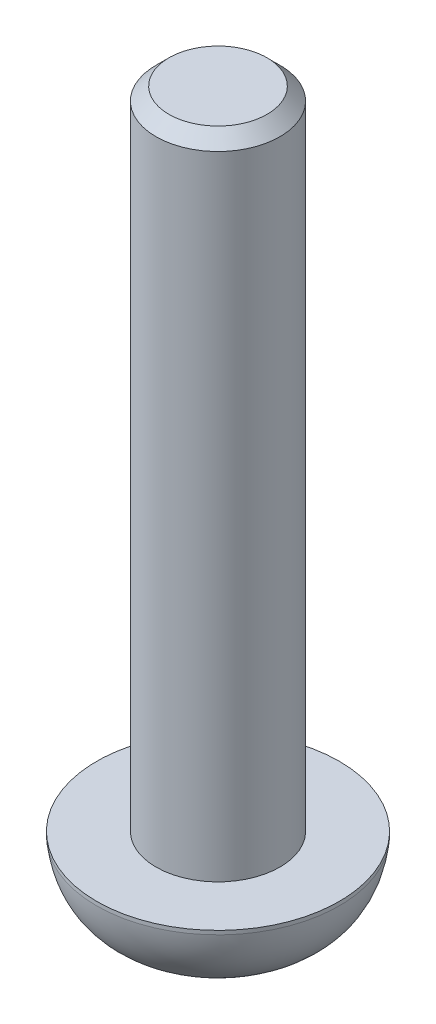
from build123d import *

# Parameters (mm, degrees)
SKETCH1_R           = 4.7
BOSS_EXTRUDE1_DEPTH = 3
SKETCH2_R           = 2.4
BOSS_EXTRUDE2_DEPTH = 25
CUT_EXTRUDE1_DEPTH  = 1.5
CHAMFER1_SIZE       = 0.5


with BuildPart() as part:
    # Sketch1 → Boss-Extrude1 (new body)
    with BuildSketch(Plane(origin=(0, 0, 0), x_dir=(1, 0, 0), z_dir=(0, 1, 0))):
        Circle(SKETCH1_R)
    extrude(amount=BOSS_EXTRUDE1_DEPTH)

    # Sketch2 → Boss-Extrude2 (add)
    with BuildSketch(Plane(origin=(0, 3, 0), x_dir=(1, 0, 0), z_dir=(0, 1, 0))):
        Circle(SKETCH2_R)
    extrude(amount=BOSS_EXTRUDE2_DEPTH)

    # Sketch3 → Cut-Revolve1 (revolve, cut)
    with BuildSketch(Plane.XY):
        with BuildLine():
            Line((2.35, 0), (4.7, 0))
            Line((4.7, 0), (4.7, 2.85))
            add(Edge.make_bspline(
                [(2.35, 0), (4.432462228, 0.599611143), (4.7, 2.85)],
                knots=[0, 0, 0, 1, 1, 1], degree=2))
        make_face()
    revolve(axis=Axis((0, 0, 0), (0, 1, 0)), mode=Mode.SUBTRACT)

    # Sketch4 → Cut-Extrude1 (cut)
    with BuildSketch(Plane.XZ):
        Polygon((0, 1.732050808), (-1.5, 0.866025404), (-1.5, -0.866025404), (0, -1.732050808), (1.5, -0.866025404), (1.5, 0.866025404), align=None)
    extrude(amount=-CUT_EXTRUDE1_DEPTH, mode=Mode.SUBTRACT)

    # Chamfer1
    chamfer1_edges = [part.edges().sort_by_distance(p)[0] for p in [
        (-2.4, 28, 0),
    ]]
    chamfer(chamfer1_edges, length=CHAMFER1_SIZE)


solid = part.part
